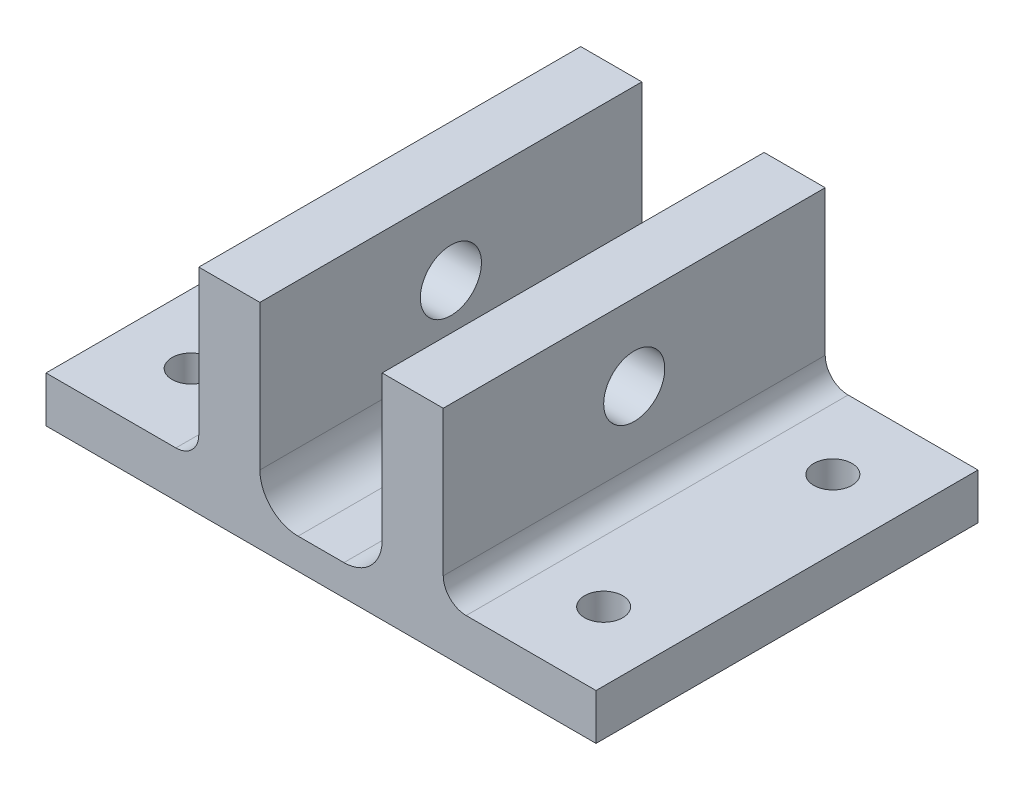
from build123d import *

# Parameters (mm, degrees)
BOSS_EXTRUDE1_DEPTH     = 25
SKETCH2_R               = 4
CUT_EXTRUDE1_DEPTH      = 45
CUT_EXTRUDE1_DEPTH_BACK = 29
FILLET1_R               = 3
FILLET2_R               = 5
SKETCH3_R               = 2.5
CUT_EXTRUDE2_DEPTH      = 25
CUT_EXTRUDE2_DEPTH_BACK = 5


with BuildPart() as part:
    # Sketch1 → Boss-Extrude1 (new body, symmetric)
    with BuildSketch(Plane.XY):
        Polygon((0, 28), (-8, 28), (-8, 4), (-24, 4), (-24, 28), (-32, 28), (-32, 6), (-52, 6), (-52, 0), (-32, 0), (0, 0), (20, 0), (20, 6), (0, 6), align=None)
    extrude(amount=BOSS_EXTRUDE1_DEPTH, both=True)

    # Sketch2 → Cut-Extrude1 (cut, two sides)
    with BuildSketch(Plane.ZY.offset(8)) as cut_extrude1_sk:
        with Locations((0, 18)):
            Circle(SKETCH2_R)
    extrude(amount=CUT_EXTRUDE1_DEPTH, mode=Mode.SUBTRACT)
    extrude(cut_extrude1_sk.sketch, amount=-CUT_EXTRUDE1_DEPTH_BACK, mode=Mode.SUBTRACT)

    # Fillet1
    fillet1_edges = [part.edges().sort_by_distance(p)[0] for p in [
        (0, 6, 0),
        (-32, 6, 0),
    ]]
    fillet(fillet1_edges, radius=FILLET1_R)

    # Fillet2
    fillet2_edges = [part.edges().sort_by_distance(p)[0] for p in [
        (-8, 4, 0),
        (-24, 4, 0),
    ]]
    fillet(fillet2_edges, radius=FILLET2_R)

    # Sketch3 → Cut-Extrude2 (cut, two sides)
    with BuildSketch(Plane(origin=(0, 4, 0), x_dir=(1, 0, 0), z_dir=(0, 1, 0))) as cut_extrude2_sk:
        with Locations((-43, 15)):
            Circle(SKETCH3_R)
        with Locations((11, 15)):
            Circle(SKETCH3_R)
        with Locations((11, -15)):
            Circle(SKETCH3_R)
        with Locations((-43, -15)):
            Circle(SKETCH3_R)
    extrude(amount=CUT_EXTRUDE2_DEPTH, mode=Mode.SUBTRACT)
    extrude(cut_extrude2_sk.sketch, amount=-CUT_EXTRUDE2_DEPTH_BACK, mode=Mode.SUBTRACT)


solid = part.part
